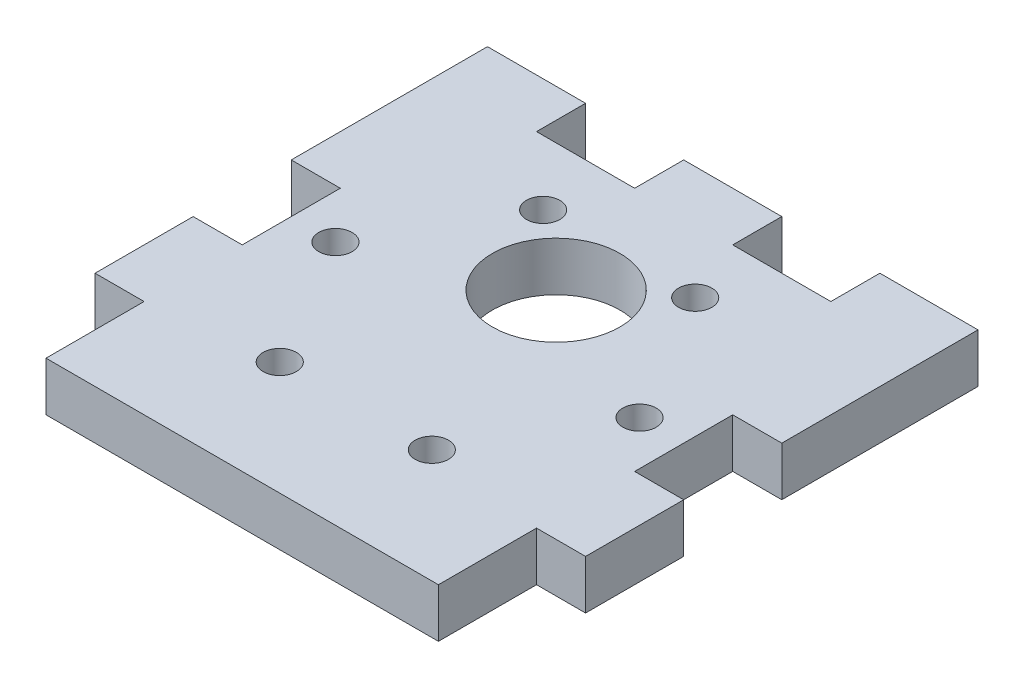
from build123d import *

# Parameters (mm, degrees)
SKETCH_1_W          = 50
SKETCH_1_H          = 50
SKETCH_1_R          = 1.7
SKETCH_1_R_2        = 6.5
EXTRUDE_1_DEPTH     = 5
SKETCH_6_W          = 10
SKETCH_6_H          = 5
SKETCH_6_W_2        = 5
SKETCH_6_H_2        = 10
CUT_EXTRUDE_1_DEPTH = 6


with BuildPart() as part:
    # 草图1 → 凸台-拉伸1 (new body)
    with BuildSketch(Plane(origin=(0, 0, 0), x_dir=(1, 0, 0), z_dir=(0, 1, 0))):
        Rectangle(SKETCH_1_W, SKETCH_1_H)
        with Locations((-15.5, 0)):
            Circle(SKETCH_1_R, mode=Mode.SUBTRACT)
        with Locations((-7.75, 13.423393759)):
            Circle(SKETCH_1_R, mode=Mode.SUBTRACT)
        with Locations((7.75, 13.423393759)):
            Circle(SKETCH_1_R, mode=Mode.SUBTRACT)
        with Locations((15.5, 0)):
            Circle(SKETCH_1_R, mode=Mode.SUBTRACT)
        with Locations((7.75, -13.423393759)):
            Circle(SKETCH_1_R, mode=Mode.SUBTRACT)
        with Locations((-7.75, -13.423393759)):
            Circle(SKETCH_1_R, mode=Mode.SUBTRACT)
        with Locations((0, 7)):
            Circle(SKETCH_1_R_2, mode=Mode.SUBTRACT)
    extrude(amount=EXTRUDE_1_DEPTH)

    # 草图6 → 切除-拉伸1 (cut, through all)
    with BuildSketch(Plane(origin=(0, 5, 0), x_dir=(1, 0, 0), z_dir=(0, 1, 0))):
        with Locations((-10, 22.5)):
            Rectangle(SKETCH_6_W, SKETCH_6_H)
        with Locations((10, 22.5)):
            Rectangle(SKETCH_6_W, SKETCH_6_H)
        with Locations((-22.5, -20)):
            Rectangle(SKETCH_6_W_2, SKETCH_6_H_2)
        with Locations((-22.5, 0)):
            Rectangle(SKETCH_6_W_2, SKETCH_6_H_2)
        with Locations((22.5, -20)):
            Rectangle(SKETCH_6_W_2, SKETCH_6_H_2)
        with Locations((22.5, 0)):
            Rectangle(SKETCH_6_W_2, SKETCH_6_H_2)
    extrude(amount=-CUT_EXTRUDE_1_DEPTH, mode=Mode.SUBTRACT)


solid = part.part
